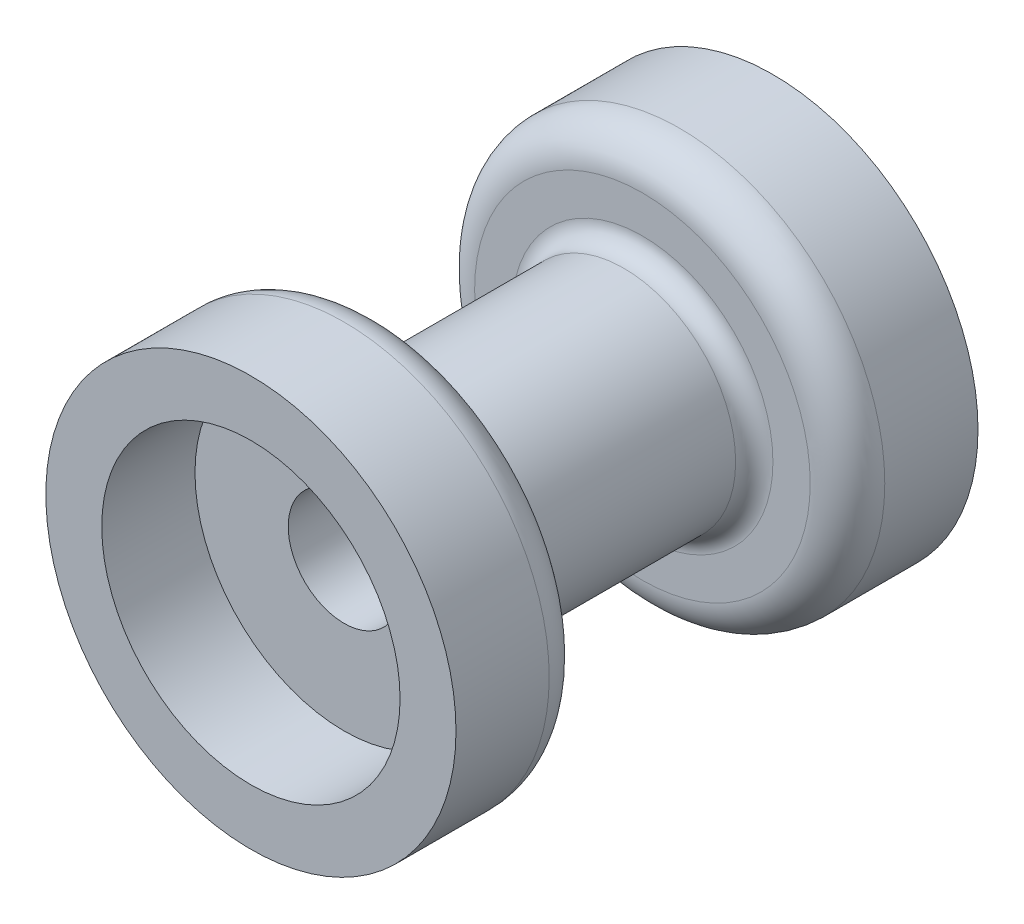
from build123d import *


with BuildPart() as part:
    # Esboço1 → Revolução1 (revolve)
    with BuildSketch(Plane(origin=(0, 0, 0), x_dir=(0, 0, -1), z_dir=(1, 0, 0))):
        with BuildLine():
            Line((0, 8), (0, 11))
            Line((0, 11), (5, 11))
            ThreePointArc((5, 11), (6.414213562, 10.414213562), (7, 9))
            Line((7, 9), (7, 7))
            ThreePointArc((7, 7), (7.292893219, 6.292893219), (8, 6))
            Line((8, 6), (20, 6))
            ThreePointArc((20, 6), (20.707106781, 6.292893219), (21, 7))
            Line((21, 7), (21, 9))
            ThreePointArc((21, 9), (21.585786438, 10.414213562), (23, 11))
            Line((23, 11), (28, 11))
            Line((28, 11), (28, 8))
            Line((28, 8), (23, 8))
            Line((23, 8), (23, 3))
            Line((23, 3), (5, 3))
            Line((5, 3), (5, 8))
            Line((5, 8), (0, 8))
        make_face()
    revolve(axis=Axis((0, 0, 0), (0, 0, -1)))


solid = part.part
